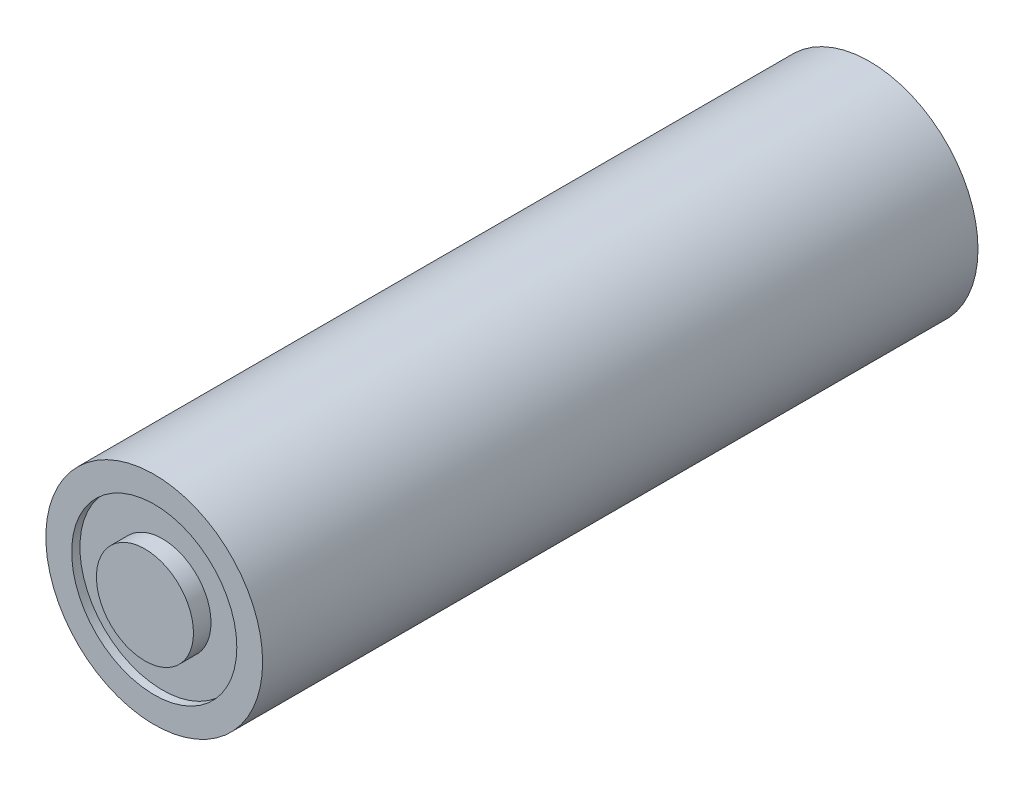
from build123d import *

# Parameters (mm, degrees)
SKETCH1_R           = 10.5
BOSS_EXTRUDE1_DEPTH = 68.50000016
SKETCH2_R           = 4.7
BOSS_EXTRUDE2_DEPTH = 1.7
SKETCH3_R           = 10.5
SKETCH3_R_2         = 8
BOSS_EXTRUDE3_DEPTH = 0.8


with BuildPart() as part:
    # Sketch1 → Boss-Extrude1 (new body)
    with BuildSketch(Plane.XY):
        Circle(SKETCH1_R)
    extrude(amount=BOSS_EXTRUDE1_DEPTH)

    # Sketch2 → Boss-Extrude2 (add)
    with BuildSketch(Plane.XY.offset(68.50000016)):
        Circle(SKETCH2_R)
    extrude(amount=BOSS_EXTRUDE2_DEPTH)

    # Sketch3 → Boss-Extrude3 (add)
    with BuildSketch(Plane.XY.offset(68.50000016)):
        Circle(SKETCH3_R)
        Circle(SKETCH3_R_2, mode=Mode.SUBTRACT)
    extrude(amount=BOSS_EXTRUDE3_DEPTH)


solid = part.part
